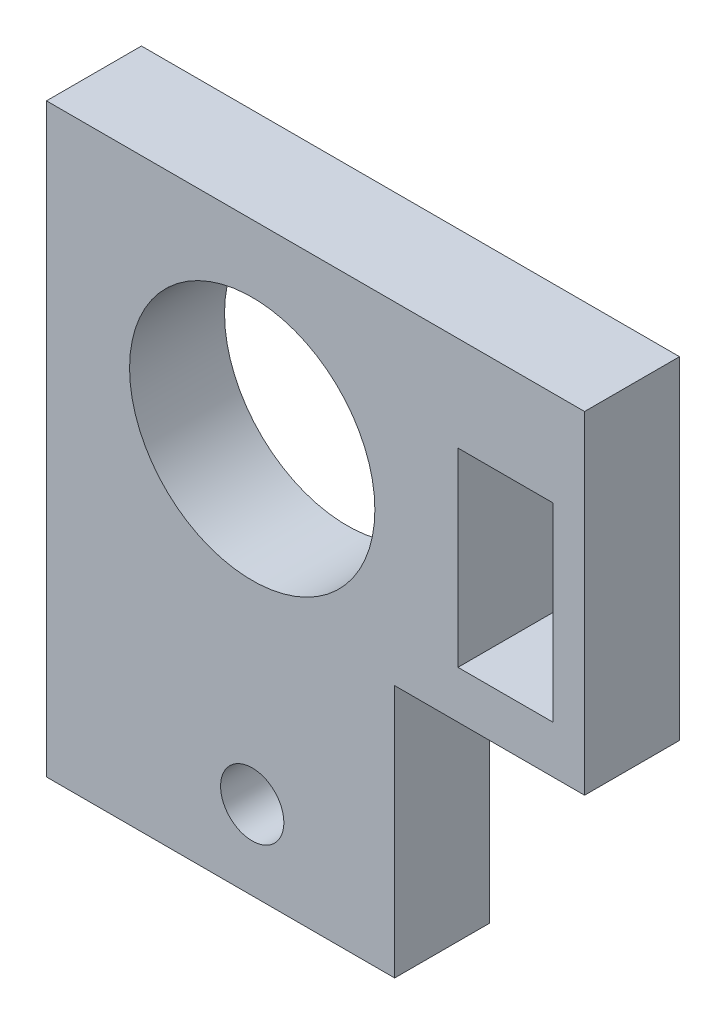
from build123d import *

# Parameters (mm, degrees)
BOSS_EXTRUDE3_DEPTH = 3
SKETCH6_W           = 3
SKETCH6_H           = 6
CUT_EXTRUDE2_DEPTH  = 3
SKETCH7_R           = 3.875
SKETCH7_R_2         = 1
CUT_EXTRUDE3_DEPTH  = 3


with BuildPart() as part:
    # Sketch3 → Boss-Extrude3 (new body)
    with BuildSketch(Plane.XY):
        Polygon((2.5, -9.25), (2.5, -1.25), (8.5, -1.25), (8.5, 9.25), (-8.5, 9.25), (-8.5, -9.25), align=None)
    extrude(amount=BOSS_EXTRUDE3_DEPTH)

    # Sketch6 → Cut-Extrude2 (cut)
    with BuildSketch(Plane.XY.offset(3)):
        with Locations((6, 3.25)):
            Rectangle(SKETCH6_W, SKETCH6_H)
    extrude(amount=-CUT_EXTRUDE2_DEPTH, mode=Mode.SUBTRACT)

    # Sketch7 → Cut-Extrude3 (cut)
    with BuildSketch(Plane.XY.offset(3)):
        with Locations((-2, 3.25)):
            Circle(SKETCH7_R)
        with Locations((-2, -6.75)):
            Circle(SKETCH7_R_2)
    extrude(amount=-CUT_EXTRUDE3_DEPTH, mode=Mode.SUBTRACT)


solid = part.part
